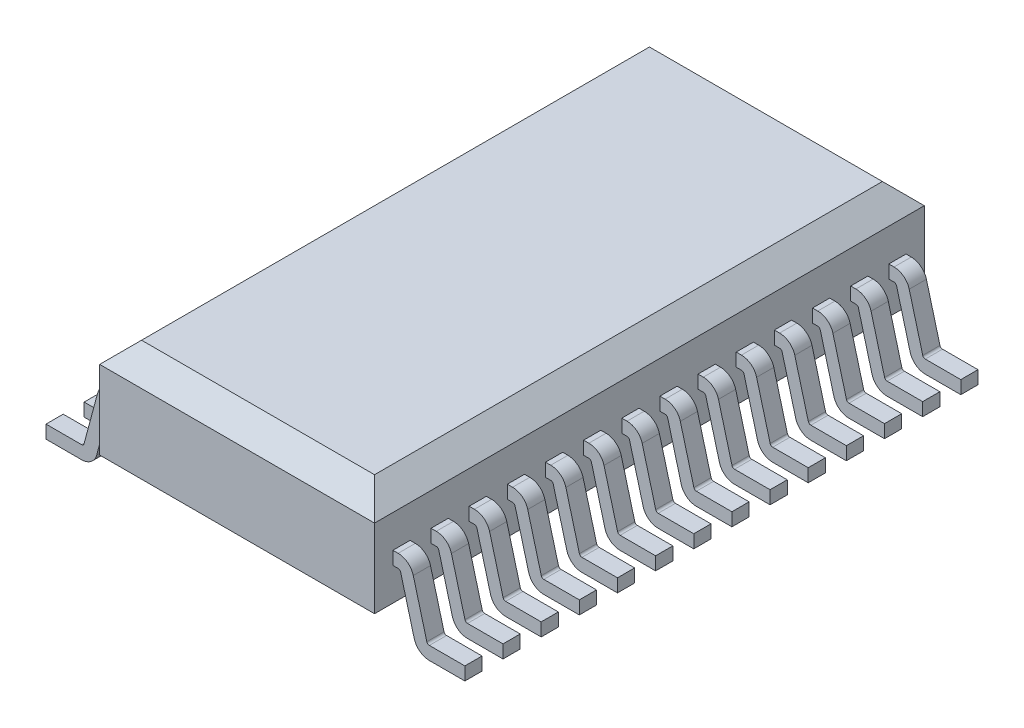
from build123d import *

# Parameters (mm, degrees)
SKETCH1_W             = 5.25
SKETCH1_H             = 2.3
BOSS_EXTRUDE1_DEPTH   = 5.25
CHAMFER1_SIZE         = 0.4
BOSS_EXTRUDE2_START   = -0.35
BOSS_EXTRUDE2_DEPTH   = 0.328571
LPATTERN1_COUNT       = 14
LPATTERN1_PITCH       = 0.7286
MIRROR1_START         = -0.35
MIRROR1_COPY_1_DEPTH  = 0.328571
MIRROR1_COPY_2_DEPTH  = 0.328571
MIRROR1_COPY_3_DEPTH  = 0.328571
MIRROR1_COPY_4_DEPTH  = 0.328571
MIRROR1_COPY_5_DEPTH  = 0.328571
MIRROR1_COPY_6_DEPTH  = 0.328571
MIRROR1_COPY_7_DEPTH  = 0.328571
MIRROR1_COPY_8_DEPTH  = 0.328571
MIRROR1_COPY_9_DEPTH  = 0.328571
MIRROR1_COPY_10_DEPTH = 0.328571
MIRROR1_COPY_11_DEPTH = 0.328571
MIRROR1_COPY_12_DEPTH = 0.328571
MIRROR1_COPY_13_DEPTH = 0.328571


with BuildPart() as part:
    # Sketch1 → Boss-Extrude1 (new body, symmetric)
    with BuildSketch(Plane.XY):
        Rectangle(SKETCH1_W, SKETCH1_H)
    extrude(amount=BOSS_EXTRUDE1_DEPTH, both=True)

    # Chamfer1
    chamfer1_edges = [part.edges().sort_by_distance(p)[0] for p in [
        (0, -1.15, 5.25),
        (0, -1.15, -5.25),
        (0, 1.15, -5.25),
        (0, 1.15, 5.25),
        (2.625, -1.15, 0),
        (-2.625, -1.15, 0),
        (-2.625, 1.15, 0),
        (2.625, 1.15, 0),
    ]]
    chamfer(chamfer1_edges, length=CHAMFER1_SIZE)

    # Sketch3 → Boss-Extrude2 (add)
    with BuildSketch(Plane.XY.offset(5.25).offset(BOSS_EXTRUDE2_START)):
        with BuildLine():
            Line((-2.625, 0.125), (-2.725, 0.125))
            ThreePointArc((-2.725, 0.125), (-2.907628429, 0.063006002), (-3.014777748, -0.097354286))
            Line((-3.014777748, -0.097354286), (-3.273505915, -1.062940952))
            ThreePointArc((-3.273505915, -1.062940952), (-3.291364135, -1.089667667), (-3.321802207, -1.1))
            Line((-3.321802207, -1.1), (-4, -1.1))
            Line((-4, -1.1), (-4, -1.35))
            Line((-4, -1.35), (-3.321802207, -1.35))
            ThreePointArc((-3.321802207, -1.35), (-3.139173778, -1.288006002), (-3.032024459, -1.127645714))
            Line((-3.032024459, -1.127645714), (-2.773296291, -0.162059048))
            ThreePointArc((-2.773296291, -0.162059048), (-2.755438071, -0.135332333), (-2.725, -0.125))
            Line((-2.725, -0.125), (-2.625, -0.125))
            Line((-2.625, -0.125), (-2.625, 0.125))
        make_face()
    boss_extrude2 = extrude(amount=-BOSS_EXTRUDE2_DEPTH)

    # LPattern1: Boss-Extrude2 ×14
    with Locations(*[(0, 0, -i * LPATTERN1_PITCH) for i in range(1, LPATTERN1_COUNT)]):
        add(boss_extrude2)

    # Mirror1: Boss-Extrude2 across plane
    add(boss_extrude2.mirror(Plane(origin=(0, 0, 0), x_dir=(0, 0, 1), z_dir=(1, 0, 0))))

    # Mirror1 copy 1 sketch → Mirror1 copy 1 (add)
    with BuildSketch(Plane(origin=(0, 0, 4.5214), x_dir=(-1, 0, 0), z_dir=(0, 0, 1)).offset(MIRROR1_START)):
        with BuildLine():
            Line((-2.625, -0.125), (-2.725, -0.125))
            ThreePointArc((-2.725, -0.125), (-2.907628429, -0.063006002), (-3.014777748, 0.097354286))
            Line((-3.014777748, 0.097354286), (-3.273505915, 1.062940952))
            ThreePointArc((-3.273505915, 1.062940952), (-3.291364135, 1.089667667), (-3.321802207, 1.1))
            Line((-3.321802207, 1.1), (-4, 1.1))
            Line((-4, 1.1), (-4, 1.35))
            Line((-4, 1.35), (-3.321802207, 1.35))
            ThreePointArc((-3.321802207, 1.35), (-3.139173778, 1.288006002), (-3.032024459, 1.127645714))
            Line((-3.032024459, 1.127645714), (-2.773296291, 0.162059048))
            ThreePointArc((-2.773296291, 0.162059048), (-2.755438071, 0.135332333), (-2.725, 0.125))
            Line((-2.725, 0.125), (-2.625, 0.125))
            Line((-2.625, 0.125), (-2.625, -0.125))
        make_face()
    extrude(amount=-MIRROR1_COPY_1_DEPTH)

    # Mirror1 copy 2 sketch → Mirror1 copy 2 (add)
    with BuildSketch(Plane(origin=(0, 0, 3.7928), x_dir=(-1, 0, 0), z_dir=(0, 0, 1)).offset(MIRROR1_START)):
        with BuildLine():
            Line((-2.625, -0.125), (-2.725, -0.125))
            ThreePointArc((-2.725, -0.125), (-2.907628429, -0.063006002), (-3.014777748, 0.097354286))
            Line((-3.014777748, 0.097354286), (-3.273505915, 1.062940952))
            ThreePointArc((-3.273505915, 1.062940952), (-3.291364135, 1.089667667), (-3.321802207, 1.1))
            Line((-3.321802207, 1.1), (-4, 1.1))
            Line((-4, 1.1), (-4, 1.35))
            Line((-4, 1.35), (-3.321802207, 1.35))
            ThreePointArc((-3.321802207, 1.35), (-3.139173778, 1.288006002), (-3.032024459, 1.127645714))
            Line((-3.032024459, 1.127645714), (-2.773296291, 0.162059048))
            ThreePointArc((-2.773296291, 0.162059048), (-2.755438071, 0.135332333), (-2.725, 0.125))
            Line((-2.725, 0.125), (-2.625, 0.125))
            Line((-2.625, 0.125), (-2.625, -0.125))
        make_face()
    extrude(amount=-MIRROR1_COPY_2_DEPTH)

    # Mirror1 copy 3 sketch → Mirror1 copy 3 (add)
    with BuildSketch(Plane(origin=(0, 0, 3.0642), x_dir=(-1, 0, 0), z_dir=(0, 0, 1)).offset(MIRROR1_START)):
        with BuildLine():
            Line((-2.625, -0.125), (-2.725, -0.125))
            ThreePointArc((-2.725, -0.125), (-2.907628429, -0.063006002), (-3.014777748, 0.097354286))
            Line((-3.014777748, 0.097354286), (-3.273505915, 1.062940952))
            ThreePointArc((-3.273505915, 1.062940952), (-3.291364135, 1.089667667), (-3.321802207, 1.1))
            Line((-3.321802207, 1.1), (-4, 1.1))
            Line((-4, 1.1), (-4, 1.35))
            Line((-4, 1.35), (-3.321802207, 1.35))
            ThreePointArc((-3.321802207, 1.35), (-3.139173778, 1.288006002), (-3.032024459, 1.127645714))
            Line((-3.032024459, 1.127645714), (-2.773296291, 0.162059048))
            ThreePointArc((-2.773296291, 0.162059048), (-2.755438071, 0.135332333), (-2.725, 0.125))
            Line((-2.725, 0.125), (-2.625, 0.125))
            Line((-2.625, 0.125), (-2.625, -0.125))
        make_face()
    extrude(amount=-MIRROR1_COPY_3_DEPTH)

    # Mirror1 copy 4 sketch → Mirror1 copy 4 (add)
    with BuildSketch(Plane(origin=(0, 0, 2.3356), x_dir=(-1, 0, 0), z_dir=(0, 0, 1)).offset(MIRROR1_START)):
        with BuildLine():
            Line((-2.625, -0.125), (-2.725, -0.125))
            ThreePointArc((-2.725, -0.125), (-2.907628429, -0.063006002), (-3.014777748, 0.097354286))
            Line((-3.014777748, 0.097354286), (-3.273505915, 1.062940952))
            ThreePointArc((-3.273505915, 1.062940952), (-3.291364135, 1.089667667), (-3.321802207, 1.1))
            Line((-3.321802207, 1.1), (-4, 1.1))
            Line((-4, 1.1), (-4, 1.35))
            Line((-4, 1.35), (-3.321802207, 1.35))
            ThreePointArc((-3.321802207, 1.35), (-3.139173778, 1.288006002), (-3.032024459, 1.127645714))
            Line((-3.032024459, 1.127645714), (-2.773296291, 0.162059048))
            ThreePointArc((-2.773296291, 0.162059048), (-2.755438071, 0.135332333), (-2.725, 0.125))
            Line((-2.725, 0.125), (-2.625, 0.125))
            Line((-2.625, 0.125), (-2.625, -0.125))
        make_face()
    extrude(amount=-MIRROR1_COPY_4_DEPTH)

    # Mirror1 copy 5 sketch → Mirror1 copy 5 (add)
    with BuildSketch(Plane(origin=(0, 0, 1.607), x_dir=(-1, 0, 0), z_dir=(0, 0, 1)).offset(MIRROR1_START)):
        with BuildLine():
            Line((-2.625, -0.125), (-2.725, -0.125))
            ThreePointArc((-2.725, -0.125), (-2.907628429, -0.063006002), (-3.014777748, 0.097354286))
            Line((-3.014777748, 0.097354286), (-3.273505915, 1.062940952))
            ThreePointArc((-3.273505915, 1.062940952), (-3.291364135, 1.089667667), (-3.321802207, 1.1))
            Line((-3.321802207, 1.1), (-4, 1.1))
            Line((-4, 1.1), (-4, 1.35))
            Line((-4, 1.35), (-3.321802207, 1.35))
            ThreePointArc((-3.321802207, 1.35), (-3.139173778, 1.288006002), (-3.032024459, 1.127645714))
            Line((-3.032024459, 1.127645714), (-2.773296291, 0.162059048))
            ThreePointArc((-2.773296291, 0.162059048), (-2.755438071, 0.135332333), (-2.725, 0.125))
            Line((-2.725, 0.125), (-2.625, 0.125))
            Line((-2.625, 0.125), (-2.625, -0.125))
        make_face()
    extrude(amount=-MIRROR1_COPY_5_DEPTH)

    # Mirror1 copy 6 sketch → Mirror1 copy 6 (add)
    with BuildSketch(Plane(origin=(0, 0, 0.8784), x_dir=(-1, 0, 0), z_dir=(0, 0, 1)).offset(MIRROR1_START)):
        with BuildLine():
            Line((-2.625, -0.125), (-2.725, -0.125))
            ThreePointArc((-2.725, -0.125), (-2.907628429, -0.063006002), (-3.014777748, 0.097354286))
            Line((-3.014777748, 0.097354286), (-3.273505915, 1.062940952))
            ThreePointArc((-3.273505915, 1.062940952), (-3.291364135, 1.089667667), (-3.321802207, 1.1))
            Line((-3.321802207, 1.1), (-4, 1.1))
            Line((-4, 1.1), (-4, 1.35))
            Line((-4, 1.35), (-3.321802207, 1.35))
            ThreePointArc((-3.321802207, 1.35), (-3.139173778, 1.288006002), (-3.032024459, 1.127645714))
            Line((-3.032024459, 1.127645714), (-2.773296291, 0.162059048))
            ThreePointArc((-2.773296291, 0.162059048), (-2.755438071, 0.135332333), (-2.725, 0.125))
            Line((-2.725, 0.125), (-2.625, 0.125))
            Line((-2.625, 0.125), (-2.625, -0.125))
        make_face()
    extrude(amount=-MIRROR1_COPY_6_DEPTH)

    # Mirror1 copy 7 sketch → Mirror1 copy 7 (add)
    with BuildSketch(Plane(origin=(0, 0, 0.1498), x_dir=(-1, 0, 0), z_dir=(0, 0, 1)).offset(MIRROR1_START)):
        with BuildLine():
            Line((-2.625, -0.125), (-2.725, -0.125))
            ThreePointArc((-2.725, -0.125), (-2.907628429, -0.063006002), (-3.014777748, 0.097354286))
            Line((-3.014777748, 0.097354286), (-3.273505915, 1.062940952))
            ThreePointArc((-3.273505915, 1.062940952), (-3.291364135, 1.089667667), (-3.321802207, 1.1))
            Line((-3.321802207, 1.1), (-4, 1.1))
            Line((-4, 1.1), (-4, 1.35))
            Line((-4, 1.35), (-3.321802207, 1.35))
            ThreePointArc((-3.321802207, 1.35), (-3.139173778, 1.288006002), (-3.032024459, 1.127645714))
            Line((-3.032024459, 1.127645714), (-2.773296291, 0.162059048))
            ThreePointArc((-2.773296291, 0.162059048), (-2.755438071, 0.135332333), (-2.725, 0.125))
            Line((-2.725, 0.125), (-2.625, 0.125))
            Line((-2.625, 0.125), (-2.625, -0.125))
        make_face()
    extrude(amount=-MIRROR1_COPY_7_DEPTH)

    # Mirror1 copy 8 sketch → Mirror1 copy 8 (add)
    with BuildSketch(Plane(origin=(0, 0, -0.5788), x_dir=(-1, 0, 0), z_dir=(0, 0, 1)).offset(MIRROR1_START)):
        with BuildLine():
            Line((-2.625, -0.125), (-2.725, -0.125))
            ThreePointArc((-2.725, -0.125), (-2.907628429, -0.063006002), (-3.014777748, 0.097354286))
            Line((-3.014777748, 0.097354286), (-3.273505915, 1.062940952))
            ThreePointArc((-3.273505915, 1.062940952), (-3.291364135, 1.089667667), (-3.321802207, 1.1))
            Line((-3.321802207, 1.1), (-4, 1.1))
            Line((-4, 1.1), (-4, 1.35))
            Line((-4, 1.35), (-3.321802207, 1.35))
            ThreePointArc((-3.321802207, 1.35), (-3.139173778, 1.288006002), (-3.032024459, 1.127645714))
            Line((-3.032024459, 1.127645714), (-2.773296291, 0.162059048))
            ThreePointArc((-2.773296291, 0.162059048), (-2.755438071, 0.135332333), (-2.725, 0.125))
            Line((-2.725, 0.125), (-2.625, 0.125))
            Line((-2.625, 0.125), (-2.625, -0.125))
        make_face()
    extrude(amount=-MIRROR1_COPY_8_DEPTH)

    # Mirror1 copy 9 sketch → Mirror1 copy 9 (add)
    with BuildSketch(Plane(origin=(0, 0, -1.3074), x_dir=(-1, 0, 0), z_dir=(0, 0, 1)).offset(MIRROR1_START)):
        with BuildLine():
            Line((-2.625, -0.125), (-2.725, -0.125))
            ThreePointArc((-2.725, -0.125), (-2.907628429, -0.063006002), (-3.014777748, 0.097354286))
            Line((-3.014777748, 0.097354286), (-3.273505915, 1.062940952))
            ThreePointArc((-3.273505915, 1.062940952), (-3.291364135, 1.089667667), (-3.321802207, 1.1))
            Line((-3.321802207, 1.1), (-4, 1.1))
            Line((-4, 1.1), (-4, 1.35))
            Line((-4, 1.35), (-3.321802207, 1.35))
            ThreePointArc((-3.321802207, 1.35), (-3.139173778, 1.288006002), (-3.032024459, 1.127645714))
            Line((-3.032024459, 1.127645714), (-2.773296291, 0.162059048))
            ThreePointArc((-2.773296291, 0.162059048), (-2.755438071, 0.135332333), (-2.725, 0.125))
            Line((-2.725, 0.125), (-2.625, 0.125))
            Line((-2.625, 0.125), (-2.625, -0.125))
        make_face()
    extrude(amount=-MIRROR1_COPY_9_DEPTH)

    # Mirror1 copy 10 sketch → Mirror1 copy 10 (add)
    with BuildSketch(Plane(origin=(0, 0, -2.036), x_dir=(-1, 0, 0), z_dir=(0, 0, 1)).offset(MIRROR1_START)):
        with BuildLine():
            Line((-2.625, -0.125), (-2.725, -0.125))
            ThreePointArc((-2.725, -0.125), (-2.907628429, -0.063006002), (-3.014777748, 0.097354286))
            Line((-3.014777748, 0.097354286), (-3.273505915, 1.062940952))
            ThreePointArc((-3.273505915, 1.062940952), (-3.291364135, 1.089667667), (-3.321802207, 1.1))
            Line((-3.321802207, 1.1), (-4, 1.1))
            Line((-4, 1.1), (-4, 1.35))
            Line((-4, 1.35), (-3.321802207, 1.35))
            ThreePointArc((-3.321802207, 1.35), (-3.139173778, 1.288006002), (-3.032024459, 1.127645714))
            Line((-3.032024459, 1.127645714), (-2.773296291, 0.162059048))
            ThreePointArc((-2.773296291, 0.162059048), (-2.755438071, 0.135332333), (-2.725, 0.125))
            Line((-2.725, 0.125), (-2.625, 0.125))
            Line((-2.625, 0.125), (-2.625, -0.125))
        make_face()
    extrude(amount=-MIRROR1_COPY_10_DEPTH)

    # Mirror1 copy 11 sketch → Mirror1 copy 11 (add)
    with BuildSketch(Plane(origin=(0, 0, -2.7646), x_dir=(-1, 0, 0), z_dir=(0, 0, 1)).offset(MIRROR1_START)):
        with BuildLine():
            Line((-2.625, -0.125), (-2.725, -0.125))
            ThreePointArc((-2.725, -0.125), (-2.907628429, -0.063006002), (-3.014777748, 0.097354286))
            Line((-3.014777748, 0.097354286), (-3.273505915, 1.062940952))
            ThreePointArc((-3.273505915, 1.062940952), (-3.291364135, 1.089667667), (-3.321802207, 1.1))
            Line((-3.321802207, 1.1), (-4, 1.1))
            Line((-4, 1.1), (-4, 1.35))
            Line((-4, 1.35), (-3.321802207, 1.35))
            ThreePointArc((-3.321802207, 1.35), (-3.139173778, 1.288006002), (-3.032024459, 1.127645714))
            Line((-3.032024459, 1.127645714), (-2.773296291, 0.162059048))
            ThreePointArc((-2.773296291, 0.162059048), (-2.755438071, 0.135332333), (-2.725, 0.125))
            Line((-2.725, 0.125), (-2.625, 0.125))
            Line((-2.625, 0.125), (-2.625, -0.125))
        make_face()
    extrude(amount=-MIRROR1_COPY_11_DEPTH)

    # Mirror1 copy 12 sketch → Mirror1 copy 12 (add)
    with BuildSketch(Plane(origin=(0, 0, -3.4932), x_dir=(-1, 0, 0), z_dir=(0, 0, 1)).offset(MIRROR1_START)):
        with BuildLine():
            Line((-2.625, -0.125), (-2.725, -0.125))
            ThreePointArc((-2.725, -0.125), (-2.907628429, -0.063006002), (-3.014777748, 0.097354286))
            Line((-3.014777748, 0.097354286), (-3.273505915, 1.062940952))
            ThreePointArc((-3.273505915, 1.062940952), (-3.291364135, 1.089667667), (-3.321802207, 1.1))
            Line((-3.321802207, 1.1), (-4, 1.1))
            Line((-4, 1.1), (-4, 1.35))
            Line((-4, 1.35), (-3.321802207, 1.35))
            ThreePointArc((-3.321802207, 1.35), (-3.139173778, 1.288006002), (-3.032024459, 1.127645714))
            Line((-3.032024459, 1.127645714), (-2.773296291, 0.162059048))
            ThreePointArc((-2.773296291, 0.162059048), (-2.755438071, 0.135332333), (-2.725, 0.125))
            Line((-2.725, 0.125), (-2.625, 0.125))
            Line((-2.625, 0.125), (-2.625, -0.125))
        make_face()
    extrude(amount=-MIRROR1_COPY_12_DEPTH)

    # Mirror1 copy 13 sketch → Mirror1 copy 13 (add)
    with BuildSketch(Plane(origin=(0, 0, -4.2218), x_dir=(-1, 0, 0), z_dir=(0, 0, 1)).offset(MIRROR1_START)):
        with BuildLine():
            Line((-2.625, -0.125), (-2.725, -0.125))
            ThreePointArc((-2.725, -0.125), (-2.907628429, -0.063006002), (-3.014777748, 0.097354286))
            Line((-3.014777748, 0.097354286), (-3.273505915, 1.062940952))
            ThreePointArc((-3.273505915, 1.062940952), (-3.291364135, 1.089667667), (-3.321802207, 1.1))
            Line((-3.321802207, 1.1), (-4, 1.1))
            Line((-4, 1.1), (-4, 1.35))
            Line((-4, 1.35), (-3.321802207, 1.35))
            ThreePointArc((-3.321802207, 1.35), (-3.139173778, 1.288006002), (-3.032024459, 1.127645714))
            Line((-3.032024459, 1.127645714), (-2.773296291, 0.162059048))
            ThreePointArc((-2.773296291, 0.162059048), (-2.755438071, 0.135332333), (-2.725, 0.125))
            Line((-2.725, 0.125), (-2.625, 0.125))
            Line((-2.625, 0.125), (-2.625, -0.125))
        make_face()
    extrude(amount=-MIRROR1_COPY_13_DEPTH)


solid = part.part
